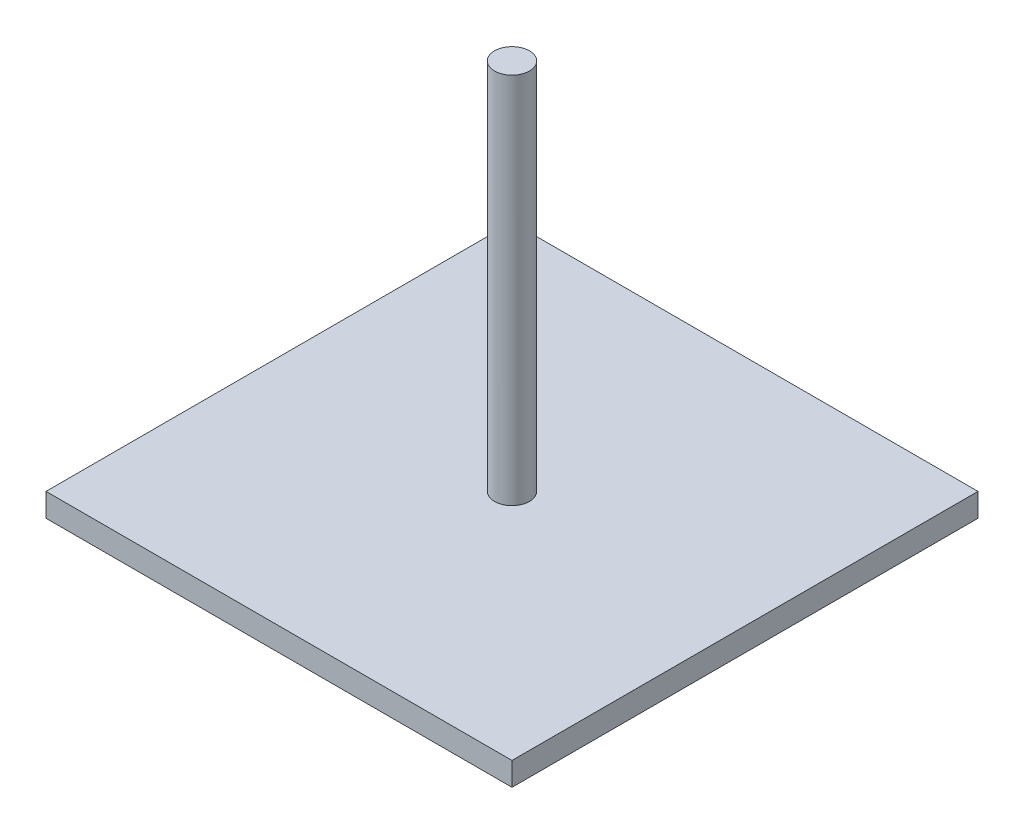
from build123d import *

# Parameters (mm, degrees)
SKETCH1_W           = 127
SKETCH1_H           = 127
BOSS_EXTRUDE1_DEPTH = 6.35
SKETCH2_R           = 4.7625
BOSS_EXTRUDE2_DEPTH = 101.6


with BuildPart() as part:
    # Sketch1 → Boss-Extrude1 (new body)
    with BuildSketch(Plane(origin=(0, 0, 0), x_dir=(1, 0, 0), z_dir=(0, 1, 0))):
        Rectangle(SKETCH1_W, SKETCH1_H)
    extrude(amount=BOSS_EXTRUDE1_DEPTH)

    # Sketch2 → Boss-Extrude2 (add)
    with BuildSketch(Plane(origin=(0, 6.35, 0), x_dir=(1, 0, 0), z_dir=(0, 1, 0))):
        Circle(SKETCH2_R)
    extrude(amount=BOSS_EXTRUDE2_DEPTH)


solid = part.part
